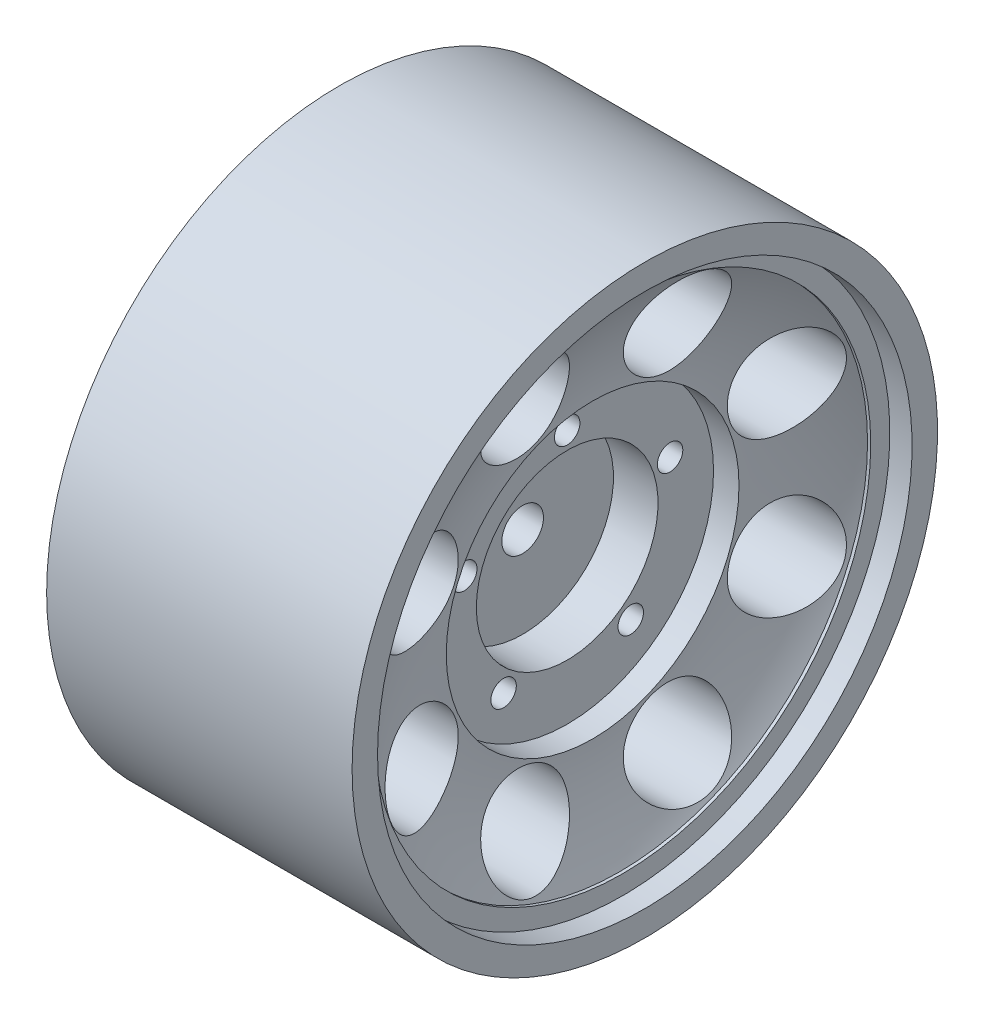
from build123d import *

# Parameters (mm, degrees)
SKETCH2_R               = 3.75
CUT_EXTRUDE2_DEPTH      = 19.15
CUT_EXTRUDE2_DEPTH_BACK = 6.85
CUT_EXTRUDE3_REACH      = 19.9
SKETCH3_R               = 1
CUT_EXTRUDE4_DEPTH      = 6.148


with BuildPart() as part:
    # Sketch1 → Revolve1 (revolve)
    with BuildSketch(Plane(origin=(0, 0, 0), x_dir=(1, 0, 0), z_dir=(0, 1, 0))):
        with BuildLine():
            Line((8.55, 1.6383), (8.55, 7.1383))
            Line((8.55, 7.1383), (12.05, 7.1383))
            Line((12.05, 7.1383), (12.05, 11.5))
            Line((12.05, 11.5), (14.05, 11.5))
            ThreePointArc((14.05, 11.5), (14.583745157, 15.635516896), (16.15, 19.5))
            Line((16.15, 19.5), (16.4, 19.5))
            Line((16.4, 19.5), (16.4, 21))
            Line((16.4, 21), (18.15, 21))
            Line((18.15, 21), (18.15, 23))
            Line((18.15, 23), (-5.85, 23))
            Line((-5.85, 23), (-5.85, 21))
            Line((-5.85, 21), (-4.35, 19.5))
            Line((-4.35, 19.5), (7, 19.5))
            Line((7, 19.5), (7, 9.75))
            Line((7, 9.75), (0, 9.75))
            Line((0, 9.75), (0, 1.6383))
            Line((0, 1.6383), (8.55, 1.6383))
        make_face()
    revolve(axis=Axis((0, 0, 0), (1, 0, 0)))

    # Sketch2 → Cut-Extrude2 (cut, two sides)
    with BuildSketch(Plane(origin=(0, 0, 0), x_dir=(0, 0, -1), z_dir=(1, 0, 0))) as cut_extrude2_sk:
        with Locations((-5.931593202, 14.320132754)):
            Circle(SKETCH2_R)
        with Locations((5.931593202, 14.320132754)):
            Circle(SKETCH2_R)
        with Locations((14.320132754, 5.931593202)):
            Circle(SKETCH2_R)
        with Locations((14.320132754, -5.931593202)):
            Circle(SKETCH2_R)
        with Locations((5.931593202, -14.320132754)):
            Circle(SKETCH2_R)
        with Locations((-5.931593202, -14.320132754)):
            Circle(SKETCH2_R)
        with Locations((-14.320132754, -5.931593202)):
            Circle(SKETCH2_R)
        with Locations((-14.320132754, 5.931593202)):
            Circle(SKETCH2_R)
    extrude(amount=CUT_EXTRUDE2_DEPTH, mode=Mode.SUBTRACT)
    extrude(cut_extrude2_sk.sketch, amount=-CUT_EXTRUDE2_DEPTH_BACK, mode=Mode.SUBTRACT)

    # Sketch3 → Cut-Extrude3 (cut, up to next)
    with BuildSketch(Plane(origin=(12.05, 0, 0), x_dir=(0, 0, -1), z_dir=(1, 0, 0)), mode=Mode.PRIVATE) as cut_extrude3_sk1:
        with Locations((0, 8.5)):
            Circle(SKETCH3_R)
    cut_extrude3_tool1 = extrude(cut_extrude3_sk1.sketch, amount=-CUT_EXTRUDE3_REACH, mode=Mode.PRIVATE) & part.part
    add(cut_extrude3_tool1.solids().sort_by_distance((12.05, 8.5, 0))[0], mode=Mode.SUBTRACT)
    # Sketch3 → Cut-Extrude3 (cut, up to next)
    with BuildSketch(Plane(origin=(12.05, 0, 0), x_dir=(0, 0, -1), z_dir=(1, 0, 0)), mode=Mode.PRIVATE) as cut_extrude3_sk2:
        with Locations((8.083980389, 2.626644452)):
            Circle(SKETCH3_R)
    cut_extrude3_tool2 = extrude(cut_extrude3_sk2.sketch, amount=-CUT_EXTRUDE3_REACH, mode=Mode.PRIVATE) & part.part
    add(cut_extrude3_tool2.solids().sort_by_distance((12.05, 2.626644, -8.08398))[0], mode=Mode.SUBTRACT)
    # Sketch3 → Cut-Extrude3 (cut, up to next)
    with BuildSketch(Plane(origin=(12.05, 0, 0), x_dir=(0, 0, -1), z_dir=(1, 0, 0)), mode=Mode.PRIVATE) as cut_extrude3_sk3:
        with Locations((4.996174644, -6.876644452)):
            Circle(SKETCH3_R)
    cut_extrude3_tool3 = extrude(cut_extrude3_sk3.sketch, amount=-CUT_EXTRUDE3_REACH, mode=Mode.PRIVATE) & part.part
    add(cut_extrude3_tool3.solids().sort_by_distance((12.05, -6.876644, -4.996175))[0], mode=Mode.SUBTRACT)
    # Sketch3 → Cut-Extrude3 (cut, up to next)
    with BuildSketch(Plane(origin=(12.05, 0, 0), x_dir=(0, 0, -1), z_dir=(1, 0, 0)), mode=Mode.PRIVATE) as cut_extrude3_sk4:
        with Locations((-4.996174644, -6.876644452)):
            Circle(SKETCH3_R)
    cut_extrude3_tool4 = extrude(cut_extrude3_sk4.sketch, amount=-CUT_EXTRUDE3_REACH, mode=Mode.PRIVATE) & part.part
    add(cut_extrude3_tool4.solids().sort_by_distance((12.05, -6.876644, 4.996175))[0], mode=Mode.SUBTRACT)
    # Sketch3 → Cut-Extrude3 (cut, up to next)
    with BuildSketch(Plane(origin=(12.05, 0, 0), x_dir=(0, 0, -1), z_dir=(1, 0, 0)), mode=Mode.PRIVATE) as cut_extrude3_sk5:
        with Locations((-8.083980389, 2.626644452)):
            Circle(SKETCH3_R)
    cut_extrude3_tool5 = extrude(cut_extrude3_sk5.sketch, amount=-CUT_EXTRUDE3_REACH, mode=Mode.PRIVATE) & part.part
    add(cut_extrude3_tool5.solids().sort_by_distance((12.05, 2.626644, 8.08398))[0], mode=Mode.SUBTRACT)

    # Sketch4 → Cut-Extrude4 (cut)
    with BuildSketch(Plane.ZY):
        Polygon((6.92820323, 0), (3.464101615, 6), (-3.464101615, 6), (-6.92820323, 0), (-3.464101615, -6), (3.464101615, -6), align=None)
    extrude(amount=-CUT_EXTRUDE4_DEPTH, mode=Mode.SUBTRACT)


solid = part.part
